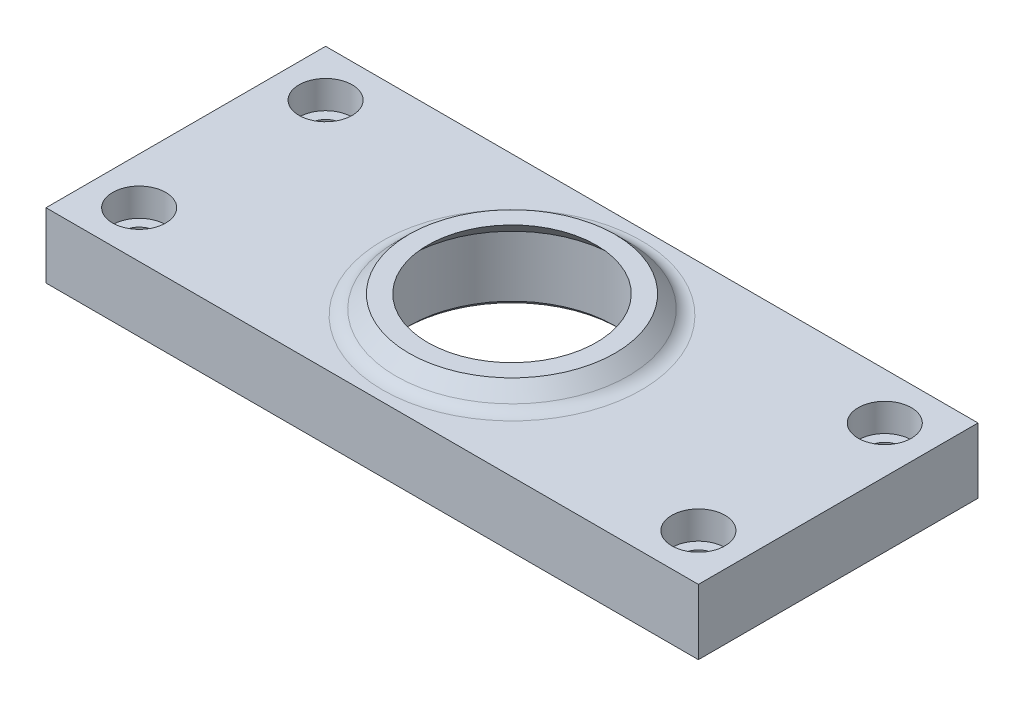
from build123d import *

# Parameters (mm, degrees)
SKETCH1_R           = 15
SKETCH1_R_2         = 11.05
BOSS_EXTRUDE1_DEPTH = 7
BOSS_EXTRUDE2_DEPTH = 7
SKETCH3_R           = 1.7
CUT_EXTRUDE1_DEPTH  = 8
SKETCH4_R           = 2.85
CUT_EXTRUDE2_DEPTH  = 3
FILLET2_R           = 2
CHAMFER1_SIZE       = 0.5


with BuildPart() as part:
    # Sketch1 → Boss-Extrude1 (new body)
    with BuildSketch(Plane(origin=(0, 0, 0), x_dir=(1, 0, 0), z_dir=(0, 1, 0))):
        Circle(SKETCH1_R)
        Circle(SKETCH1_R_2, mode=Mode.SUBTRACT)
    extrude(amount=BOSS_EXTRUDE1_DEPTH)

    # Sketch2 → Boss-Extrude2 (add)
    with BuildSketch(Plane(origin=(0, 7, 0), x_dir=(1, 0, 0), z_dir=(0, 1, 0))):
        with BuildLine():
            Line((0, -15), (-35, -15))
            Line((-35, -15), (-35, 15))
            Line((-35, 15), (0, 15))
            ThreePointArc((0, 15), (-15, 0), (0, -15))
        make_face()
    boss_extrude2 = extrude(amount=-BOSS_EXTRUDE2_DEPTH)

    # Sketch3 → Cut-Extrude1 (cut, through all)
    with BuildSketch(Plane(origin=(0, 7, 0), x_dir=(1, 0, 0), z_dir=(0, 1, 0))):
        with Locations((-30, 10)):
            Circle(SKETCH3_R)
        with Locations((-30, -10)):
            Circle(SKETCH3_R)
    cut_extrude1 = extrude(amount=-CUT_EXTRUDE1_DEPTH, mode=Mode.SUBTRACT)

    # Sketch4 → Cut-Extrude2 (cut)
    with BuildSketch(Plane(origin=(0, 7, 0), x_dir=(1, 0, 0), z_dir=(0, 1, 0))):
        with Locations((-30, 10)):
            Circle(SKETCH4_R)
        with Locations((-30, -10)):
            Circle(SKETCH4_R)
    cut_extrude2 = extrude(amount=-CUT_EXTRUDE2_DEPTH, mode=Mode.SUBTRACT)

    # Mirror1: Boss-Extrude2, Cut-Extrude1, Cut-Extrude2 across plane
    add(boss_extrude2.mirror(Plane(origin=(0, 0, 0), x_dir=(0, 0, 1), z_dir=(1, 0, 0))))
    add(cut_extrude1.mirror(Plane(origin=(0, 0, 0), x_dir=(0, 0, 1), z_dir=(1, 0, 0))), mode=Mode.SUBTRACT)
    add(cut_extrude2.mirror(Plane(origin=(0, 0, 0), x_dir=(0, 0, 1), z_dir=(1, 0, 0))), mode=Mode.SUBTRACT)

    # Sketch6 → Revolve1 (revolve)
    with BuildSketch(Plane.XY):
        Polygon((11.05, 7), (9.05, 9), (11.05, 9), (13.05, 7), align=None)
    revolve(axis=Axis((0, 7, 0), (0, -1, 0)))

    # Fillet2
    fillet2_edges = [part.edges().sort_by_distance(p)[0] for p in [
        (-13.05, 7, 0),
    ]]
    fillet(fillet2_edges, radius=FILLET2_R)

    # Chamfer1
    chamfer1_edges = [part.edges().sort_by_distance(p)[0] for p in [
        (-11.05, 0, 0),
    ]]
    chamfer(chamfer1_edges, length=CHAMFER1_SIZE)


solid = part.part
